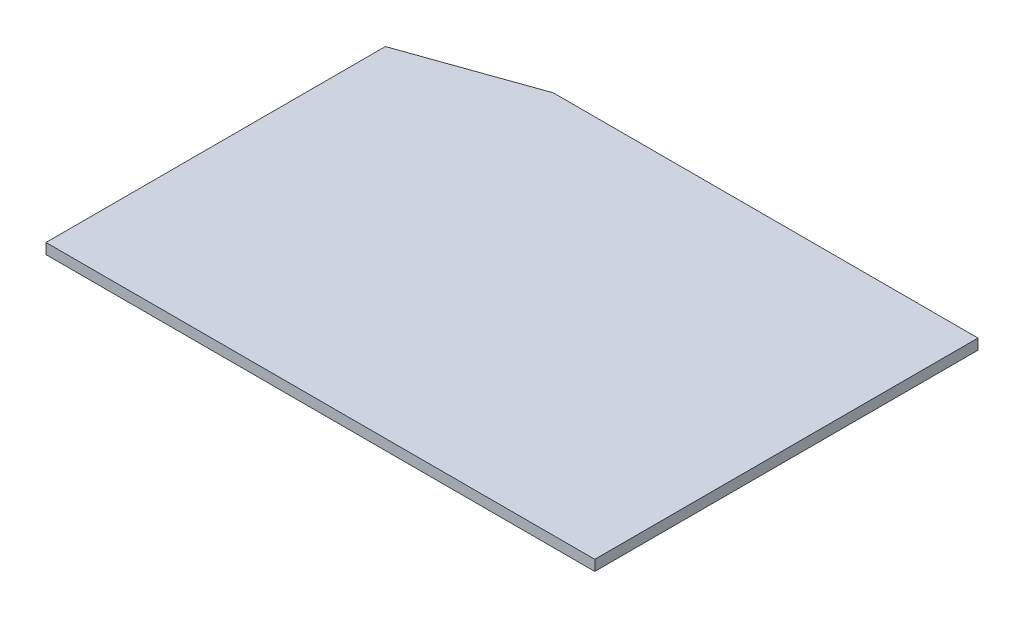
from build123d import *

# Parameters (mm, degrees)
BOSS_EXTRU_1_DEPTH = 2


with BuildPart() as part:
    # Esquisse1 → Boss.-Extru.1 (new body)
    with BuildSketch(Plane(origin=(0, 0, 0), x_dir=(1, 0, 0), z_dir=(0, 1, 0))):
        Polygon((0, 0), (104.149727965, 0), (104.149727965, 72.735324071), (23.534335447, 72.735324071), (0, 64.406533629), align=None)
    extrude(amount=BOSS_EXTRU_1_DEPTH)


solid = part.part
